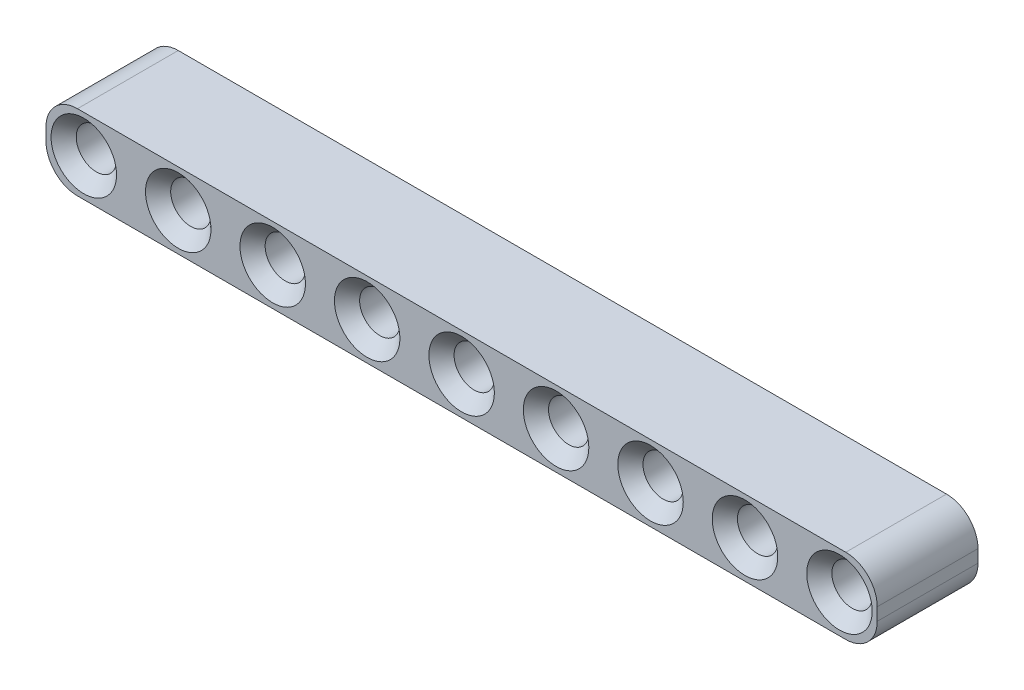
from build123d import *

# Parameters (mm, degrees)
SKETCH1_R           = 1.6
BOSS_EXTRUDE1_DEPTH = 8
CHAMFER1_SIZE       = 1


with BuildPart() as part:
    # Sketch1 → Boss-Extrude1 (new body)
    with BuildSketch(Plane.XY):
        with BuildLine():
            Line((-0.5, 3), (60.5, 3))
            ThreePointArc((60.5, 3), (62.267766953, 2.267766953), (63, 0.5))
            Line((63, 0.5), (63, -0.5))
            ThreePointArc((63, -0.5), (62.267766953, -2.267766953), (60.5, -3))
            Line((60.5, -3), (-0.5, -3))
            ThreePointArc((-0.5, -3), (-2.267766953, -2.267766953), (-3, -0.5))
            Line((-3, -0.5), (-3, 0.5))
            ThreePointArc((-3, 0.5), (-2.267766953, 2.267766953), (-0.5, 3))
        make_face()
        Circle(SKETCH1_R, mode=Mode.SUBTRACT)
        with Locations((7.5, 0)):
            Circle(SKETCH1_R, mode=Mode.SUBTRACT)
        with Locations((15, 0)):
            Circle(SKETCH1_R, mode=Mode.SUBTRACT)
        with Locations((22.5, 0)):
            Circle(SKETCH1_R, mode=Mode.SUBTRACT)
        with Locations((30, 0)):
            Circle(SKETCH1_R, mode=Mode.SUBTRACT)
        with Locations((37.5, 0)):
            Circle(SKETCH1_R, mode=Mode.SUBTRACT)
        with Locations((45, 0)):
            Circle(SKETCH1_R, mode=Mode.SUBTRACT)
        with Locations((52.5, 0)):
            Circle(SKETCH1_R, mode=Mode.SUBTRACT)
        with Locations((60, 0)):
            Circle(SKETCH1_R, mode=Mode.SUBTRACT)
    extrude(amount=BOSS_EXTRUDE1_DEPTH)

    # Chamfer1
    chamfer1_edges = [part.edges().sort_by_distance(p)[0] for p in [
        (-1.6, 0, 0),
        (-1.6, 0, 8),
        (5.9, 0, 0),
        (5.9, 0, 8),
        (13.4, 0, 0),
        (13.4, 0, 8),
        (20.9, 0, 0),
        (20.9, 0, 8),
        (28.4, 0, 0),
        (28.4, 0, 8),
        (35.9, 0, 0),
        (35.9, 0, 8),
        (43.4, 0, 0),
        (43.4, 0, 8),
        (50.9, 0, 0),
        (50.9, 0, 8),
        (58.4, 0, 0),
        (58.4, 0, 8),
    ]]
    chamfer(chamfer1_edges, length=CHAMFER1_SIZE)


solid = part.part
